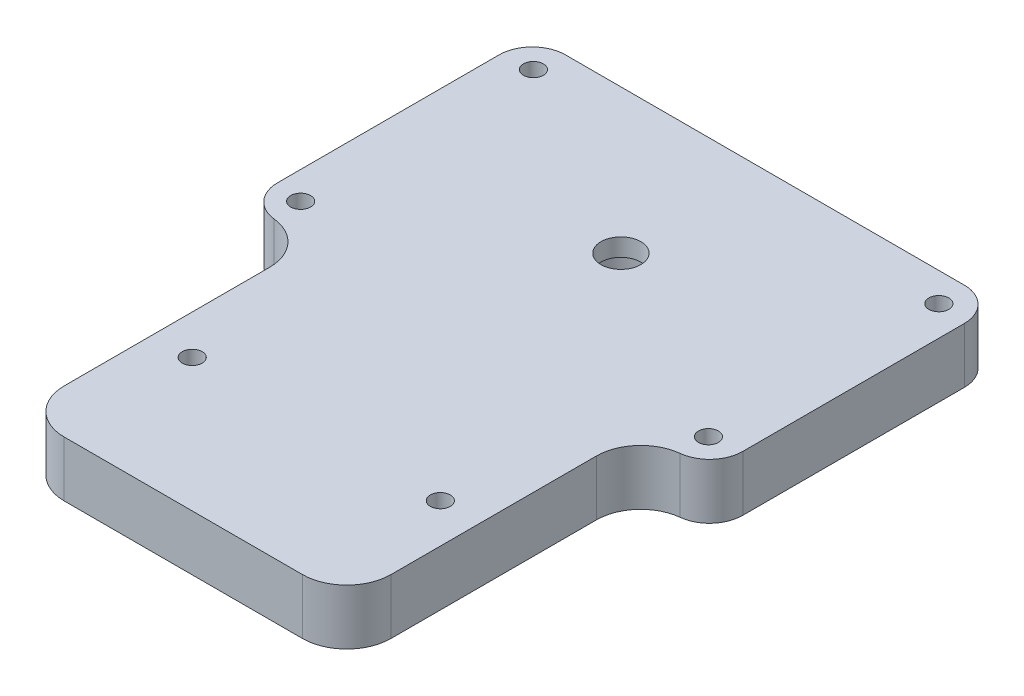
from build123d import *

# Parameters (mm, degrees)
SKETCH1_R           = 1.143
BOSS_EXTRUDE1_DEPTH = 6.35
SKETCH2_R           = 3.81
CUT_EXTRUDE1_DEPTH  = 4.318
SKETCH3_R           = 2.286
CUT_EXTRUDE2_DEPTH  = 4.318
FILLET1_R           = 5.08


with BuildPart() as part:
    # Sketch1 → Boss-Extrude1 (new body)
    with BuildSketch(Plane(origin=(0, 0, 0), x_dir=(1, 0, 0), z_dir=(0, 1, 0))):
        with BuildLine():
            Line((-22.86, 16.51), (22.86, 16.51))
            ThreePointArc((22.86, 16.51), (25.554076836, 15.394076836), (26.67, 12.7))
            Line((26.67, 12.7), (26.67, -12.7))
            ThreePointArc((26.67, -12.7), (25.554076836, -15.394076836), (22.86, -16.51))
            Line((22.86, -16.51), (18.7325, -16.51))
            Line((18.7325, -16.51), (18.7325, -50.165))
            Line((18.7325, -50.165), (-18.7325, -50.165))
            Line((-18.7325, -50.165), (-18.7325, -16.51))
            Line((-18.7325, -16.51), (-22.86, -16.51))
            ThreePointArc((-22.86, -16.51), (-25.554076836, -15.394076836), (-26.67, -12.7))
            Line((-26.67, -12.7), (-26.67, 12.7))
            ThreePointArc((-26.67, 12.7), (-25.554076836, 15.394076836), (-22.86, 16.51))
        make_face()
        with Locations((-23.241, 13.208)):
            Circle(SKETCH1_R, mode=Mode.SUBTRACT)
        with Locations((23.241, 13.208)):
            Circle(SKETCH1_R, mode=Mode.SUBTRACT)
        with Locations((23.241, -13.208)):
            Circle(SKETCH1_R, mode=Mode.SUBTRACT)
        with Locations((-23.50753981, -13.208)):
            Circle(SKETCH1_R, mode=Mode.SUBTRACT)
        with Locations((14.224, -34.925)):
            Circle(SKETCH1_R, mode=Mode.SUBTRACT)
        with Locations((-14.224, -34.925)):
            Circle(SKETCH1_R, mode=Mode.SUBTRACT)
    extrude(amount=BOSS_EXTRUDE1_DEPTH)

    # Sketch2 → Cut-Extrude1 (cut)
    with BuildSketch(Plane.XZ):
        Circle(SKETCH2_R)
    extrude(amount=-CUT_EXTRUDE1_DEPTH, mode=Mode.SUBTRACT)

    # Sketch3 → Cut-Extrude2 (cut)
    with BuildSketch(Plane(origin=(0, 4.318, 0), x_dir=(-1, 0, 0), z_dir=(0, -1, 0))):
        Circle(SKETCH3_R)
    extrude(amount=-CUT_EXTRUDE2_DEPTH, mode=Mode.SUBTRACT)

    # Fillet1
    fillet1_edges = [part.edges().sort_by_distance(p)[0] for p in [
        (-18.7325, 3.175, 16.51),
        (18.7325, 3.175, 16.51),
        (18.7325, 3.175, 50.165),
        (-18.7325, 3.175, 50.165),
    ]]
    fillet(fillet1_edges, radius=FILLET1_R)


solid = part.part
